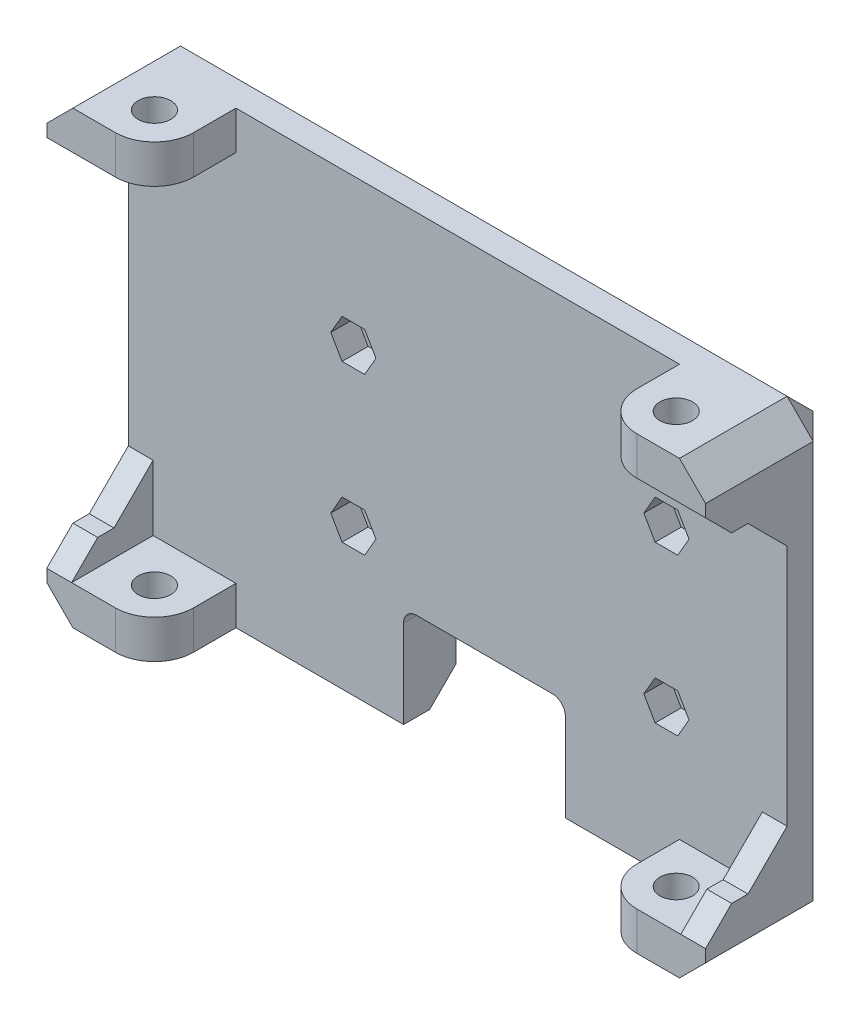
from build123d import *

# Parameters (mm, degrees)
SKETCH1_W           = 46.5
SKETCH1_H           = 34.5
BOSS_EXTRUDE1_DEPTH = 4
SKETCH2_W           = 46.5
SKETCH2_H           = 2.95
BOSS_EXTRUDE2_DEPTH = 6.5
SKETCH3_R           = 1.25
CUT_EXTRUDE1_DEPTH  = 35.5
CUT_EXTRUDE8_DEPTH  = 35.5
SKETCH5_R           = 0.725
CUT_EXTRUDE3_DEPTH  = 11.25
SKETCH21_W          = 12.4
SKETCH21_H          = 8.2
CUT_EXTRUDE11_DEPTH = 11.25
BOSS_EXTRUDE3_DEPTH = 0.1
BOSS_EXTRUDE4_DEPTH = 0.1
SKETCH17_W          = 10.25
SKETCH17_H          = 34.5
BOSS_EXTRUDE6_DEPTH = 1.9
SKETCH18_W          = 10.25
SKETCH18_H          = 34.5
BOSS_EXTRUDE7_DEPTH = 1.9
CUT_EXTRUDE10_DEPTH = 51.5
CHAMFER1_SIZE       = 2
FILLET2_R           = 1
CUT_EXTRUDE12_DEPTH = 2


with BuildPart() as part:
    # Sketch1 → Boss-Extrude1 (new body)
    with BuildSketch(Plane.XY):
        Rectangle(SKETCH1_W, SKETCH1_H)
    extrude(amount=BOSS_EXTRUDE1_DEPTH)

    # Sketch2 → Boss-Extrude2 (add)
    with BuildSketch(Plane.XY.offset(4)):
        with Locations((0, 15.775)):
            Rectangle(SKETCH2_W, SKETCH2_H)
        with Locations((0, -15.775)):
            Rectangle(SKETCH2_W, SKETCH2_H)
    extrude(amount=BOSS_EXTRUDE2_DEPTH)

    # Sketch3 → Cut-Extrude1 (cut, through all)
    with BuildSketch(Plane(origin=(0, 17.25, 0), x_dir=(1, 0, 0), z_dir=(0, 1, 0))):
        with Locations((-20, -7.25)):
            Circle(SKETCH3_R)
        with Locations((20, -7.25)):
            Circle(SKETCH3_R)
    extrude(amount=-CUT_EXTRUDE1_DEPTH, mode=Mode.SUBTRACT)

    # Sketch11 → Cut-Extrude8 (cut, through all)
    with BuildSketch(Plane(origin=(0, 17.25, 0), x_dir=(1, 0, 0), z_dir=(0, 1, 0))):
        with BuildLine():
            Line((-17, -7.25), (-17, -4))
            Line((-17, -4), (17, -4))
            Line((17, -4), (17, -7.25))
            ThreePointArc((17, -7.25), (17.878679656, -9.371320344), (20, -10.25))
            Line((20, -10.25), (23.25, -10.25))
            Line((23.25, -10.25), (23.25, -10.5))
            Line((23.25, -10.5), (-23.25, -10.5))
            Line((-23.25, -10.5), (-23.25, -10.25))
            Line((-23.25, -10.25), (-20, -10.25))
            ThreePointArc((-20, -10.25), (-17.878679656, -9.371320344), (-17, -7.25))
        make_face()
    extrude(amount=-CUT_EXTRUDE8_DEPTH, mode=Mode.SUBTRACT)

    # Sketch5 → Cut-Extrude3 (cut, through all)
    with BuildSketch(Plane(origin=(0, 0, 0), x_dir=(-1, 0, 0), z_dir=(0, 0, -1))):
        with Locations((8, 6)):
            Circle(SKETCH5_R)
        with Locations((8, -6)):
            Circle(SKETCH5_R)
        with Locations((-16, -6)):
            Circle(SKETCH5_R)
        with Locations((-16, 6)):
            Circle(SKETCH5_R)
    extrude(amount=-CUT_EXTRUDE3_DEPTH, mode=Mode.SUBTRACT)

    # Sketch21 → Cut-Extrude11 (cut, through all)
    with BuildSketch(Plane(origin=(0, 0, 0), x_dir=(-1, 0, 0), z_dir=(0, 0, -1))):
        with Locations((-2.05, -13.6)):
            Rectangle(SKETCH21_W, SKETCH21_H)
    extrude(amount=-CUT_EXTRUDE11_DEPTH, mode=Mode.SUBTRACT)

    # Sketch14 → Boss-Extrude3 (add)
    with BuildSketch(Plane.ZY.offset(23.25)):
        Polygon((10.25, 17.25), (0, 17.25), (0, -17.25), (10.25, -17.25), (10.25, -14.3), (4, -14.3), (4, 14.3), (10.25, 14.3), align=None)
    extrude(amount=BOSS_EXTRUDE3_DEPTH)

    # Sketch15 → Boss-Extrude4 (add)
    with BuildSketch(Plane(origin=(23.25, 0, 0), x_dir=(0, 0, -1), z_dir=(1, 0, 0))):
        Polygon((-10.25, -17.25), (0, -17.25), (0, 17.25), (-10.25, 17.25), (-10.25, 14.3), (-4, 14.3), (-4, -14.3), (-10.25, -14.3), align=None)
    extrude(amount=BOSS_EXTRUDE4_DEPTH)

    # Sketch17 → Boss-Extrude6 (add)
    with BuildSketch(Plane.ZY.offset(23.35)):
        with Locations((5.125, 0)):
            Rectangle(SKETCH17_W, SKETCH17_H)
    extrude(amount=BOSS_EXTRUDE6_DEPTH)

    # Sketch18 → Boss-Extrude7 (add)
    with BuildSketch(Plane(origin=(23.35, 0, 0), x_dir=(0, 0, -1), z_dir=(1, 0, 0))):
        with Locations((-5.125, 0)):
            Rectangle(SKETCH18_W, SKETCH18_H)
    extrude(amount=BOSS_EXTRUDE7_DEPTH)

    # Sketch19 → Cut-Extrude10 (cut, through all)
    with BuildSketch(Plane.ZY.offset(25.25)):
        Polygon((10.25, 12.3), (7, 12.3), (4, 9.3), (4, -9.3), (7, -12.3), (10.25, -12.3), align=None)
    extrude(amount=-CUT_EXTRUDE10_DEPTH, mode=Mode.SUBTRACT)

    # Chamfer1
    chamfer1_edges = [part.edges().sort_by_distance(p)[0] for p in [
        (16.75, -17.25, 0),
        (-25.25, 0, 0),
        (-25.25, -17.25, 5.125),
        (-25.25, 17.25, 5.125),
        (25.25, 0, 0),
        (25.25, 17.25, 5.125),
        (25.25, -17.25, 5.125),
        (-24.3, 12.3, 10.25),
        (-24.3, -12.3, 10.25),
        (24.3, 12.3, 10.25),
        (24.3, -12.3, 10.25),
        (0, 17.25, 0),
        (-14.7, -17.25, 0),
    ]]
    chamfer(chamfer1_edges, length=CHAMFER1_SIZE)

    # Fillet2
    fillet2_edges = [part.edges().sort_by_distance(p)[0] for p in [
        (-4.15, -9.5, 2),
        (8.25, -9.5, 2),
    ]]
    fillet(fillet2_edges, radius=FILLET2_R)

    # Sketch22 → Cut-Extrude12 (cut)
    with BuildSketch(Plane.XY.offset(4)):
        Polygon((-7.133974596, 4.5), (-6.267949192, 6), (-7.133974596, 7.5), (-8.866025404, 7.5), (-9.732050808, 6), (-8.866025404, 4.5), align=None)
        Polygon((-7.133974596, -7.5), (-6.267949192, -6), (-7.133974596, -4.5), (-8.866025404, -4.5), (-9.732050808, -6), (-8.866025404, -7.5), align=None)
        Polygon((16.866025404, -7.5), (17.732050808, -6), (16.866025404, -4.5), (15.133974596, -4.5), (14.267949192, -6), (15.133974596, -7.5), align=None)
        Polygon((16.866025404, 4.5), (17.732050808, 6), (16.866025404, 7.5), (15.133974596, 7.5), (14.267949192, 6), (15.133974596, 4.5), align=None)
    extrude(amount=-CUT_EXTRUDE12_DEPTH, mode=Mode.SUBTRACT)


solid = part.part
